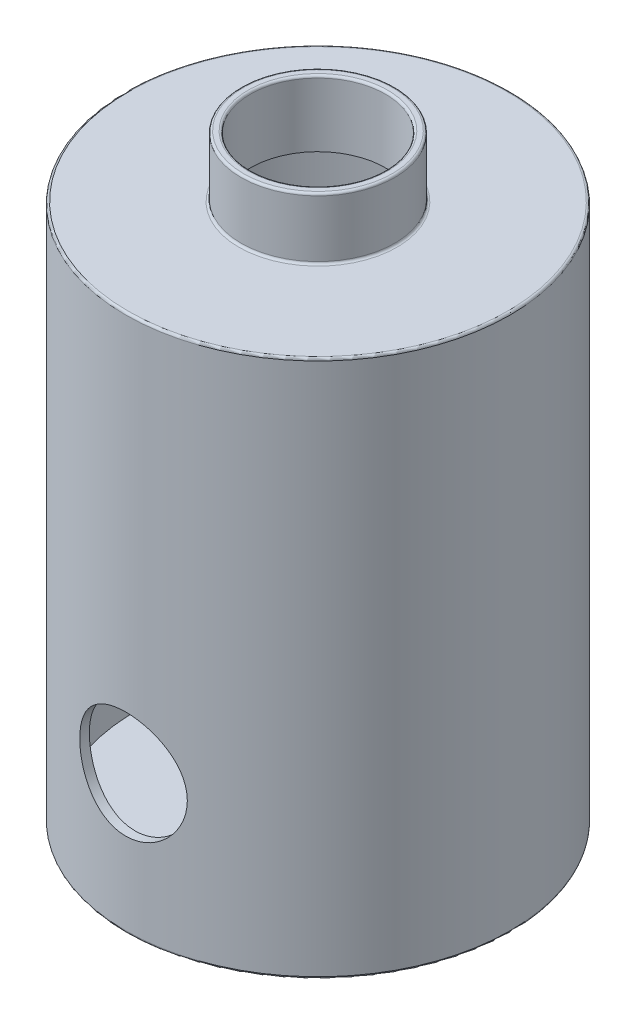
from build123d import *

# Parameters (mm, degrees)
SKETCH1_R               = 62.5
BOSS_EXTRUDE1_DEPTH     = 175
CUT_EXTRUDE1_START      = -1.5
SKETCH2_R               = 59.5
CUT_EXTRUDE1_DEPTH      = 172
SKETCH3_R               = 25
BOSS_EXTRUDE2_DEPTH     = 20
SKETCH4_R               = 22
CUT_EXTRUDE2_DEPTH      = 30
FILLET1_R               = 0.75
SKETCH5_R               = 17.5
CUT_EXTRUDE3_DEPTH      = 63.5000001
CUT_EXTRUDE3_DEPTH_BACK = 70


with BuildPart() as part:
    # Sketch1 → Boss-Extrude1 (new body)
    with BuildSketch(Plane(origin=(0, 0, 0), x_dir=(1, 0, 0), z_dir=(0, 1, 0))):
        Circle(SKETCH1_R)
    extrude(amount=BOSS_EXTRUDE1_DEPTH)

    # Sketch2 → Cut-Extrude1 (cut)
    with BuildSketch(Plane(origin=(0, 175, 0), x_dir=(1, 0, 0), z_dir=(0, 1, 0)).offset(CUT_EXTRUDE1_START)):
        Circle(SKETCH2_R)
    extrude(amount=-CUT_EXTRUDE1_DEPTH, mode=Mode.SUBTRACT)

    # Sketch3 → Boss-Extrude2 (add)
    with BuildSketch(Plane(origin=(0, 175, 0), x_dir=(1, 0, 0), z_dir=(0, 1, 0))):
        Circle(SKETCH3_R)
    extrude(amount=BOSS_EXTRUDE2_DEPTH)

    # Sketch4 → Cut-Extrude2 (cut)
    with BuildSketch(Plane(origin=(0, 195, 0), x_dir=(1, 0, 0), z_dir=(0, 1, 0))):
        Circle(SKETCH4_R)
    extrude(amount=-CUT_EXTRUDE2_DEPTH, mode=Mode.SUBTRACT)

    # Fillet1
    fillet1_edges = [part.edges().sort_by_distance(p)[0] for p in [
        (-25, 175, 0),
        (-25, 195, 0),
        (-22, 195, 0),
        (-62.5, 0, 0),
        (-62.5, 175, 0),
    ]]
    fillet(fillet1_edges, radius=FILLET1_R)

    # Sketch5 → Cut-Extrude3 (cut, two sides)
    with BuildSketch(Plane.XY) as cut_extrude3_sk:
        with Locations((0, 44.895186866)):
            Circle(SKETCH5_R)
    extrude(amount=CUT_EXTRUDE3_DEPTH, mode=Mode.SUBTRACT)
    extrude(cut_extrude3_sk.sketch, amount=-CUT_EXTRUDE3_DEPTH_BACK, mode=Mode.SUBTRACT)


solid = part.part
